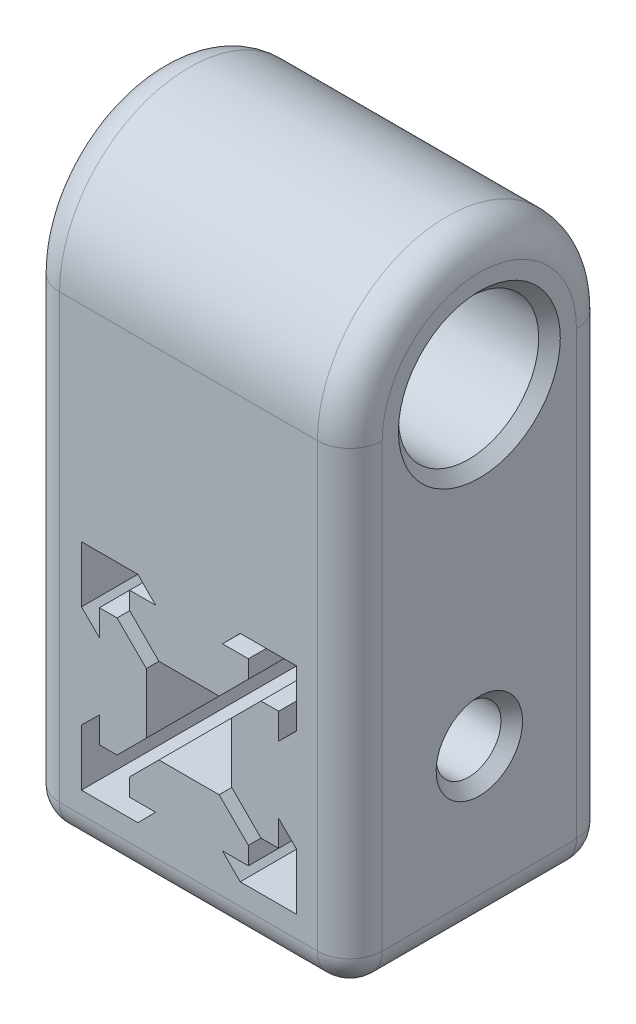
from build123d import *

# Parameters (mm, degrees)
BOSS_EXTRUDE1_DEPTH = 24
SKETCH5_R           = 6.5
BOSS_EXTRUDE3_DEPTH = 29.899298
SKETCH3_R           = 3
CUT_EXTRUDE1_DEPTH  = 30.899298428
FILLET1_R           = 3
CHAMFER1_SIZE       = 1


with BuildPart() as part:
    # Sketch1 → Boss-Extrude1 (new body)
    with BuildSketch(Plane.XY):
        Polygon((0, 15), (14.899298428, 15), (14.899298428, -14.949649214), (-15, -14.949649214), (-15, 15), align=None)
        Polygon((-9.966432809, 9.966432809), (-4.741432809, 9.966432809), (-3.1, 8.307461143), (-5.5, 8.307461143), (-5.5, 6.667461143), (-2.79, 3.957461143), (2.79, 3.957461143), (5.5, 6.667461143), (5.5, 8.307461143), (3.1, 8.307461143), (4.741432809, 9.966432809), (9.966432809, 9.966432809), (9.966432809, 4.741432809), (8.307461143, 3.1), (8.307461143, 5.5), (6.667461143, 5.5), (3.957461143, 2.79), (3.957461143, -2.79), (6.667461143, -5.5), (8.307461143, -5.5), (8.307461143, -3.1), (9.966432809, -4.741432809), (9.966432809, -9.966432809), (4.741432809, -9.966432809), (3.1, -8.307461143), (5.5, -8.307461143), (5.5, -6.667461143), (2.79, -3.957461143), (-2.79, -3.957461143), (-5.5, -6.667461143), (-5.5, -8.307461143), (-3.1, -8.307461143), (-4.741432809, -9.966432809), (-9.966432809, -9.966432809), (-9.966432809, -4.741432809), (-8.307461143, -3.1), (-8.307461143, -5.5), (-6.667461143, -5.5), (-3.957461143, -2.79), (-3.957461143, 2.79), (-6.667461143, 5.5), (-8.307461143, 5.5), (-8.307461143, 3.1), (-9.966432809, 4.741432809), align=None, mode=Mode.SUBTRACT)
    extrude(amount=BOSS_EXTRUDE1_DEPTH)

    # Sketch5 → Boss-Extrude3 (add, through all)
    with BuildSketch(Plane.ZY.offset(15)):
        with BuildLine():
            Line((0, 15), (0, 22.5))
            Line((0, 22.5), (0, 29))
            ThreePointArc((0, 29), (12, 41), (24, 29))
            Line((24, 29), (24, 22.5))
            Line((24, 22.5), (24, 15))
            Line((24, 15), (0, 15))
        make_face()
        with Locations((12, 29)):
            Circle(SKETCH5_R, mode=Mode.SUBTRACT)
    extrude(amount=-BOSS_EXTRUDE3_DEPTH)

    # Sketch3 → Cut-Extrude1 (cut, through all)
    with BuildSketch(Plane.ZY.offset(15)):
        with Locations((12, 0)):
            Circle(SKETCH3_R)
    extrude(amount=-CUT_EXTRUDE1_DEPTH, mode=Mode.SUBTRACT)

    # Fillet1
    fillet1_edges = [part.edges().sort_by_distance(p)[0] for p in [
        (-0.050350786, -14.949649214, 24),
        (14.899298214, 7.025175393, 24),
        (14.899298, 41, 12),
        (-15, 41, 12),
        (14.899298428, 0.025175393, 0),
        (-0.050350786, -14.949649214, 0),
        (-15, 7.025175393, 0),
        (-15, 7.025175393, 24),
        (14.899298428, -14.949649214, 12),
        (-15, -14.949649214, 12),
    ]]
    fillet(fillet1_edges, radius=FILLET1_R)

    # Chamfer1
    chamfer1_edges = [part.edges().sort_by_distance(p)[0] for p in [
        (14.899298, 29, 5.5),
        (-15, 29, 5.5),
        (14.899298428, 0, 9),
        (-15, 0, 9),
    ]]
    chamfer(chamfer1_edges, length=CHAMFER1_SIZE)


solid = part.part
